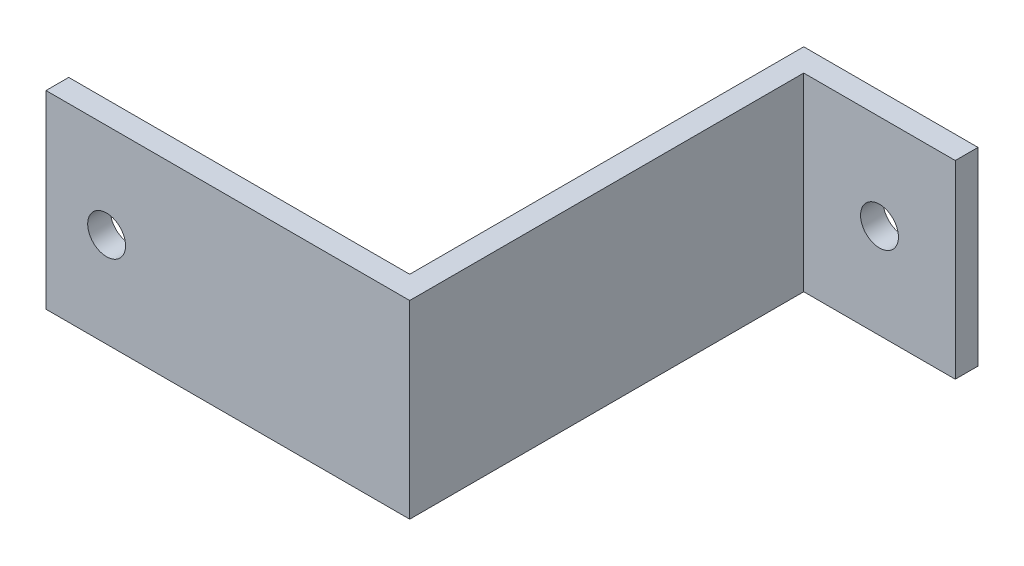
from build123d import *

# Parameters (mm, degrees)
BOSS_EXTRUDE1_DEPTH = 25
SKETCH2_R           = 2.5
CUT_EXTRUDE1_DEPTH  = 68


with BuildPart() as part:
    # Sketch1 → Boss-Extrude1 (new body)
    with BuildSketch(Plane(origin=(0, 0, 0), x_dir=(1, 0, 0), z_dir=(0, 1, 0))):
        Polygon((0, 0), (20, 0), (20, -3), (0, -3), (0, -55), (-18, -55), (-48, -55), (-48, -52), (-3, -52), (-3, 0), align=None)
    extrude(amount=BOSS_EXTRUDE1_DEPTH)

    # Sketch2 → Cut-Extrude1 (cut)
    with BuildSketch(Plane.XY.offset(55)):
        with Locations((-40, 12.5)):
            Circle(SKETCH2_R)
        with Locations((10, 12.5)):
            Circle(SKETCH2_R)
    extrude(amount=-CUT_EXTRUDE1_DEPTH, mode=Mode.SUBTRACT)


solid = part.part
